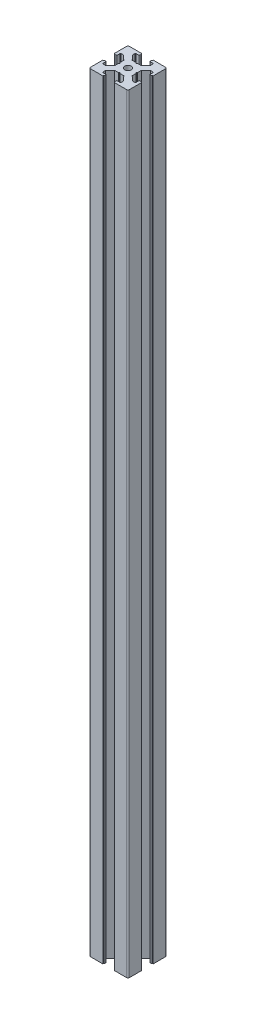
from build123d import *

# Parameters (mm, degrees)
BOSS_EXTRUDE1_DEPTH = 594
FILLET1_R           = 1
SKETCH4_R           = 2.5
CUT_EXTRUDE1_DEPTH  = 595
FILLET2_R           = 0.5


with BuildPart() as part:
    # Sketch3 → Boss-Extrude1 (new body)
    with BuildSketch(Plane(origin=(0, 0, 0), x_dir=(1, 0, 0), z_dir=(0, 1, 0))):
        with BuildLine():
            Line((11, 27.75), (11, 29.5))
            ThreePointArc((11, 29.5), (10.646446609, 29.646446609), (10.5, 30))
            Line((10.5, 30), (0, 30))
            Line((0, 30), (0, 19.5))
            ThreePointArc((0, 19.5), (0.353553391, 19.353553391), (0.5, 19))
            Line((0.5, 19), (2.25, 19))
            Line((2.25, 19), (2.25, 22))
            Line((2.25, 22), (4.5, 22))
            Line((4.5, 22), (8.25, 18.5))
            Line((8.25, 18.5), (8.25, 15.5))
            Line((8.25, 15.5), (8.75, 15))
            Line((8.75, 15), (8.25, 14.5))
            Line((8.25, 14.5), (8.25, 11.5))
            Line((8.25, 11.5), (4.5, 8))
            Line((4.5, 8), (2.25, 8))
            Line((2.25, 8), (2.25, 11))
            Line((2.25, 11), (0.5, 11))
            ThreePointArc((0.5, 11), (0.353553391, 10.646446609), (0, 10.5))
            Line((0, 10.5), (0, 0))
            Line((0, 0), (10.5, 0))
            ThreePointArc((10.5, 0), (10.646446609, 0.353553391), (11, 0.5))
            Line((11, 0.5), (11, 2.25))
            Line((11, 2.25), (8, 2.25))
            Line((8, 2.25), (8, 4.5))
            Line((8, 4.5), (11.5, 8.25))
            Line((11.5, 8.25), (14.5, 8.25))
            Line((14.5, 8.25), (15, 8.75))
            Line((15, 8.75), (15.5, 8.25))
            Line((15.5, 8.25), (18.5, 8.25))
            Line((18.5, 8.25), (22, 4.5))
            Line((22, 4.5), (22, 2.25))
            Line((22, 2.25), (19, 2.25))
            Line((19, 2.25), (19, 0.5))
            ThreePointArc((19, 0.5), (19.353553391, 0.353553391), (19.5, 0))
            Line((19.5, 0), (30, 0))
            Line((30, 0), (30, 10.5))
            ThreePointArc((30, 10.5), (29.646446609, 10.646446609), (29.5, 11))
            Line((29.5, 11), (27.75, 11))
            Line((27.75, 11), (27.75, 8))
            Line((27.75, 8), (25.5, 8))
            Line((25.5, 8), (21.75, 11.5))
            Line((21.75, 11.5), (21.75, 14.5))
            Line((21.75, 14.5), (21.25, 15))
            Line((21.25, 15), (21.75, 15.5))
            Line((21.75, 15.5), (21.75, 18.5))
            Line((21.75, 18.5), (25.5, 22))
            Line((25.5, 22), (27.75, 22))
            Line((27.75, 22), (27.75, 19))
            Line((27.75, 19), (29.5, 19))
            ThreePointArc((29.5, 19), (29.646446609, 19.353553391), (30, 19.5))
            Line((30, 19.5), (30, 30))
            Line((30, 30), (19.5, 30))
            ThreePointArc((19.5, 30), (19.353553391, 29.646446609), (19, 29.5))
            Line((19, 29.5), (19, 27.75))
            Line((19, 27.75), (22, 27.75))
            Line((22, 27.75), (22, 25.5))
            Line((22, 25.5), (18.5, 21.75))
            Line((18.5, 21.75), (15.5, 21.75))
            Line((15.5, 21.75), (15, 21.25))
            Line((15, 21.25), (14.5, 21.75))
            Line((14.5, 21.75), (11.5, 21.75))
            Line((11.5, 21.75), (8, 25.5))
            Line((8, 25.5), (8, 27.75))
            Line((8, 27.75), (11, 27.75))
        make_face()
    extrude(amount=BOSS_EXTRUDE1_DEPTH)

    # Fillet1
    fillet1_edges = [part.edges().sort_by_distance(p)[0] for p in [
        (30, 297, 0),
        (0, 297, 0),
        (0, 297, -30),
        (30, 297, -30),
    ]]
    fillet(fillet1_edges, radius=FILLET1_R)

    # Sketch4 → Cut-Extrude1 (cut, through all)
    with BuildSketch(Plane(origin=(0, 594, 0), x_dir=(1, 0, 0), z_dir=(0, 1, 0))):
        with Locations((15, 15)):
            Circle(SKETCH4_R)
    extrude(amount=-CUT_EXTRUDE1_DEPTH, mode=Mode.SUBTRACT)

    # Fillet2
    fillet2_edges = [part.edges().sort_by_distance(p)[0] for p in [
        (27.75, 297, -19),
        (27.75, 297, -22),
        (21.75, 297, -15.5),
        (21.75, 297, -14.5),
        (27.75, 297, -8),
        (27.75, 297, -11),
        (19, 297, -2.25),
        (22, 297, -2.25),
        (15.5, 297, -8.25),
        (14.5, 297, -8.25),
        (8, 297, -2.25),
        (11, 297, -2.25),
        (2.25, 297, -11),
        (2.25, 297, -8),
        (8.25, 297, -14.5),
        (8.25, 297, -15.5),
        (2.25, 297, -22),
        (2.25, 297, -19),
        (11, 297, -27.75),
        (8, 297, -27.75),
        (14.5, 297, -21.75),
        (15.5, 297, -21.75),
        (22, 297, -27.75),
        (19, 297, -27.75),
    ]]
    fillet(fillet2_edges, radius=FILLET2_R)


solid = part.part
